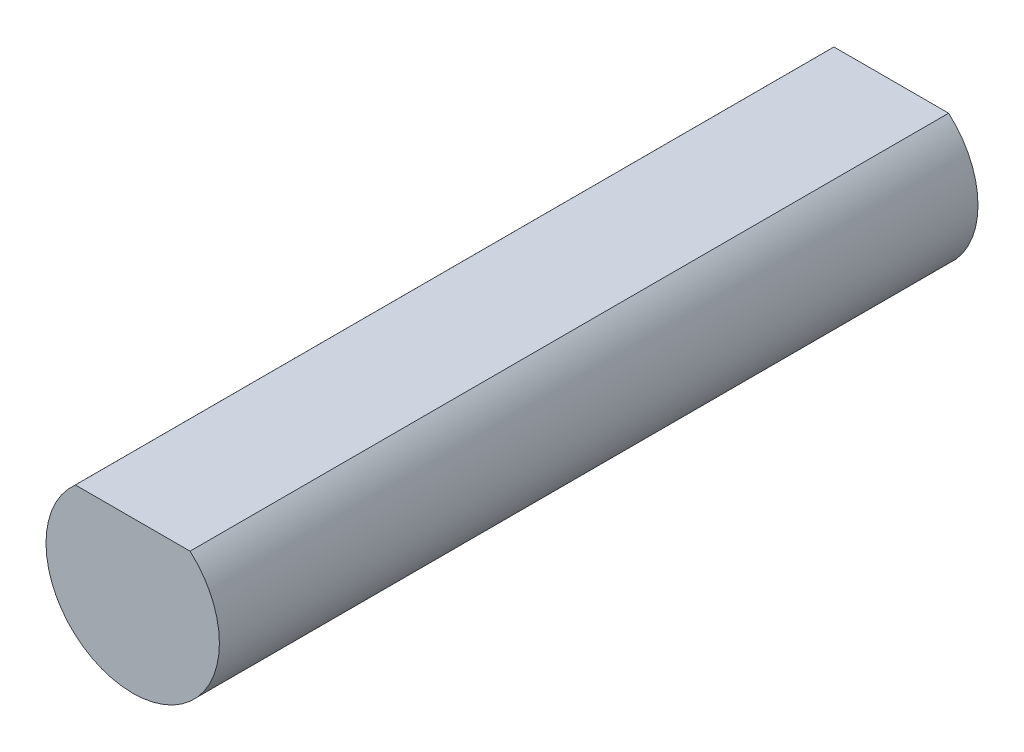
from build123d import *

# Parameters (mm, degrees)
SKETCH2_R                      = 4
BOSS_EXTRUDE1_DEPTH            = 35
CUT_EXTRUDE1_REACH             = 37
CUT_EXTRUDE1_DIRECTION_2_DEPTH = 1


with BuildPart() as part:
    # Sketch2 → Boss-Extrude1 (new body)
    with BuildSketch(Plane.XY):
        Circle(SKETCH2_R)
    extrude(amount=BOSS_EXTRUDE1_DEPTH)

    # Sketch3 → Cut-Extrude1 (cut, up to next)
    with BuildSketch(Plane.XY.offset(35), mode=Mode.PRIVATE) as cut_extrude1_sk1:
        with BuildLine():
            Line((-2.645751311, 3), (2.645751311, 3))
            ThreePointArc((2.645751311, 3), (0, 4), (-2.645751311, 3))
        make_face()
    cut_extrude1_tool1 = extrude(cut_extrude1_sk1.sketch, amount=-CUT_EXTRUDE1_REACH, mode=Mode.PRIVATE) & part.part
    add(cut_extrude1_tool1.solids().sort_by_distance((0, 3.404621, 35))[0], mode=Mode.SUBTRACT)

    # Sketch3 → Cut-Extrude1 direction 2 (cut)
    with BuildSketch(Plane.XY.offset(35)):
        with BuildLine():
            Line((-2.645751311, 3), (2.645751311, 3))
            ThreePointArc((2.645751311, 3), (0, 4), (-2.645751311, 3))
        make_face()
    extrude(amount=CUT_EXTRUDE1_DIRECTION_2_DEPTH, mode=Mode.SUBTRACT)


solid = part.part
